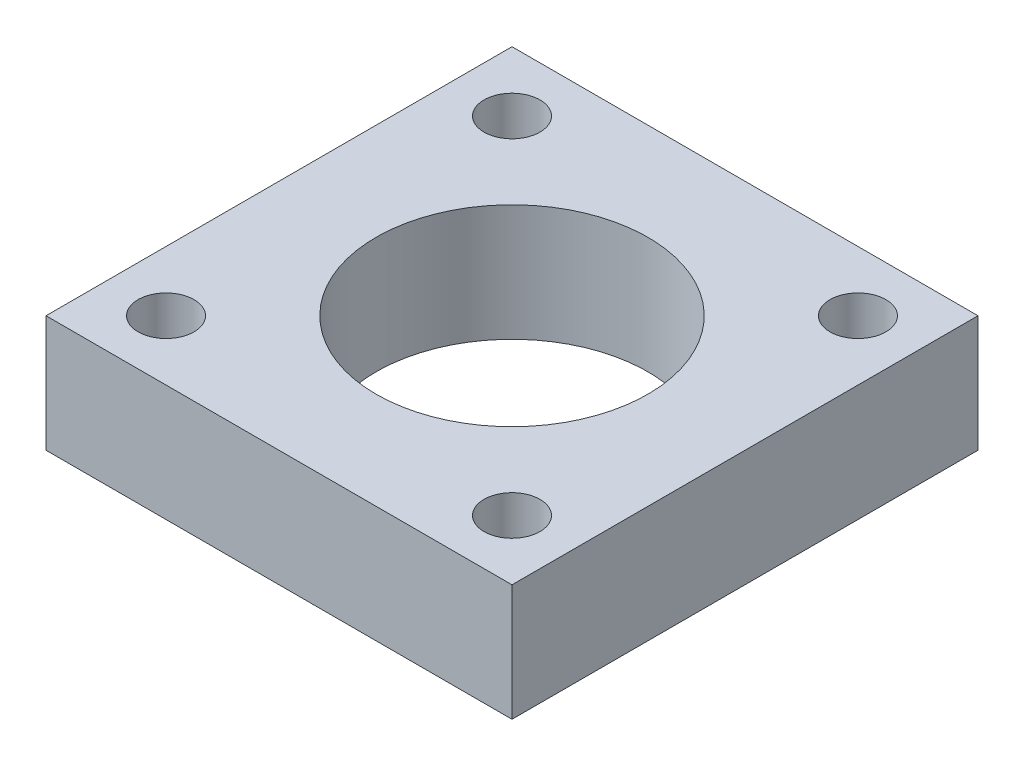
from build123d import *

# Parameters (mm, degrees)
SKETCH1_W           = 38.1
SKETCH1_H           = 38.1
SKETCH1_R           = 2.286
SKETCH1_R_2         = 11.1125
BOSS_EXTRUDE1_DEPTH = 9.525


with BuildPart() as part:
    # Sketch1 → Boss-Extrude1 (new body)
    with BuildSketch(Plane(origin=(0, 0, 0), x_dir=(1, 0, 0), z_dir=(0, 1, 0))):
        Rectangle(SKETCH1_W, SKETCH1_H)
        with Locations((14.142135624, 14.142135624)):
            Circle(SKETCH1_R, mode=Mode.SUBTRACT)
        with Locations((14.142135624, -14.142135624)):
            Circle(SKETCH1_R, mode=Mode.SUBTRACT)
        with Locations((-14.142135624, -14.142135624)):
            Circle(SKETCH1_R, mode=Mode.SUBTRACT)
        with Locations((-14.142135624, 14.142135624)):
            Circle(SKETCH1_R, mode=Mode.SUBTRACT)
        Circle(SKETCH1_R_2, mode=Mode.SUBTRACT)
    extrude(amount=BOSS_EXTRUDE1_DEPTH)


solid = part.part
